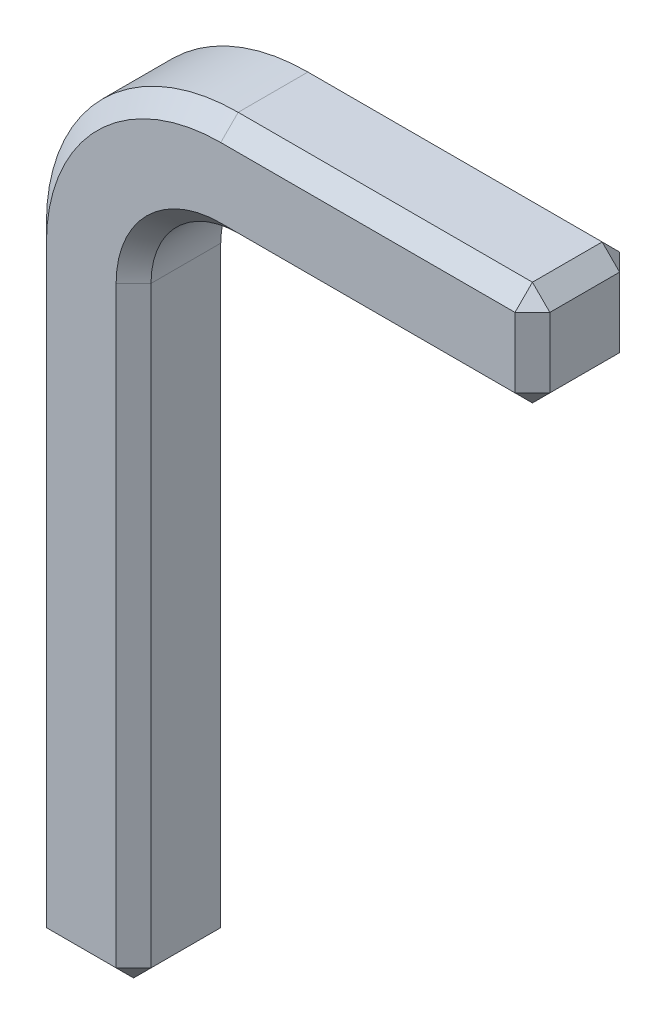
from build123d import *

# Parameters (mm, degrees)
BOSS_EXTRUDE1_DEPTH = 0.3
CHAMFER1_SIZE       = 0.1


with BuildPart() as part:
    # Sketch1 → Boss-Extrude1 (new body, symmetric)
    with BuildSketch(Plane.XY):
        with BuildLine():
            Line((-0.6, 0), (-0.6, 3.5))
            ThreePointArc((-0.6, 3.5), (-0.277817459, 4.277817459), (0.5, 4.6))
            Line((0.5, 4.6), (2.287695887, 4.6))
            Line((2.287695887, 4.6), (2.287695887, 4))
            Line((2.287695887, 4), (0.5, 4))
            ThreePointArc((0.5, 4), (0.146446609, 3.853553391), (0, 3.5))
            Line((0, 3.5), (0, 0))
            Line((0, 0), (-0.6, 0))
        make_face()
    extrude(amount=BOSS_EXTRUDE1_DEPTH, both=True)

    # Chamfer1
    chamfer1_edges = [part.edges().sort_by_distance(p)[0] for p in [
        (0.146446609, 3.853553391, 0.3),
        (0, 1.75, -0.3),
        (-0.3, 0, -0.3),
        (1.393847944, 4, 0.3),
        (-0.6, 0, 0),
        (2.287695887, 4.6, 0),
        (2.287695887, 4, 0),
        (0, 0, 0),
        (2.287695887, 4.3, 0.3),
        (1.393847944, 4.6, 0.3),
        (-0.277817459, 4.277817459, 0.3),
        (-0.6, 1.75, 0.3),
        (-0.3, 0, 0.3),
        (0, 1.75, 0.3),
        (-0.6, 1.75, -0.3),
        (-0.277817459, 4.277817459, -0.3),
        (1.393847944, 4.6, -0.3),
        (2.287695887, 4.3, -0.3),
        (1.393847944, 4, -0.3),
        (0.146446609, 3.853553391, -0.3),
    ]]
    chamfer(chamfer1_edges, length=CHAMFER1_SIZE)


solid = part.part
